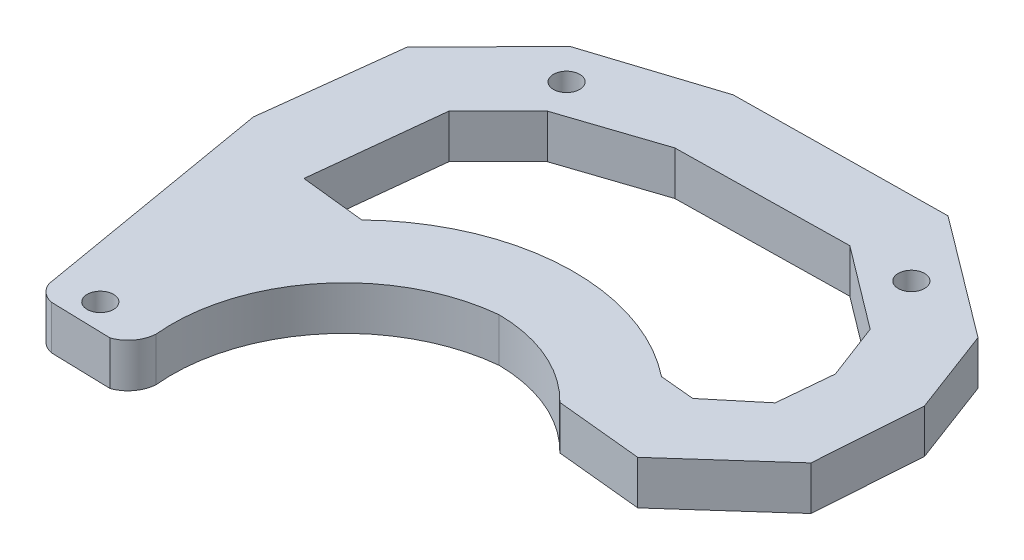
from build123d import *

# Parameters (mm, degrees)
BOSS_EXTRUDE2_DEPTH = 5
SKETCH2_R           = 1.5
CUT_EXTRUDE1_DEPTH  = 15


with BuildPart() as part:
    # Sketch1 → Boss-Extrude2 (new body)
    with BuildSketch(Plane(origin=(0, 0, 0), x_dir=(1, 0, 0), z_dir=(0, 1, 0))):
        with BuildLine():
            Line((1.569728042, 52.040332943), (15.651301799, 56.559771658))
            Line((15.651301799, 56.559771658), (39.856221019, 56.858644564))
            Line((39.856221019, 56.858644564), (53.599377939, 46.535137731))
            Line((53.599377939, 46.535137731), (57.29105631, 36.738583337))
            Line((57.29105631, 36.738583337), (56.448543902, 24.628756692))
            Line((56.448543902, 24.628756692), (46.012568554, 15.301947443))
            Line((46.012568554, 15.301947443), (36.148543795, 16.282769063))
            ThreePointArc((36.148543795, 16.282769063), (30.610071526, 20.095537749), (24.030369651, 21.480963085))
            ThreePointArc((24.030369651, 21.480963085), (10.748506444, 14.399234116), (6.364349479, 0))
            ThreePointArc((6.364349479, 0), (5.689983794, -1.843684392), (4.107122834, -3.004930446))
            Line((4.107122834, -3.004930446), (-2.771373889, -2.820272816))
            ThreePointArc((-2.771373889, -2.820272816), (-3.97819548, -2.210628496), (-4.733361209, -1.089107533))
            Line((-4.733361209, -1.089107533), (-9.544633948, 27.008719122))
            Line((-9.544633948, 27.008719122), (-7.668325905, 42.684434119))
            Line((-7.668325905, 42.684434119), (1.569728042, 52.040332943))
        make_face()
        with BuildLine():
            Line((1.036932163, 38.743694932), (-0.578535299, 23.81135118))
            Line((-0.578535299, 23.81135118), (6.824389086, 23.010459929))
            ThreePointArc((6.824389086, 23.010459929), (22.804886304, 29.960497456), (39.395602183, 24.628756692))
            Line((39.395602183, 24.628756692), (43.340115732, 24.258511233))
            Line((43.340115732, 24.258511233), (48.476214586, 28.525175745))
            Line((48.476214586, 28.525175745), (49.056861781, 34.804762264))
            Line((49.056861781, 34.804762264), (46.61935743, 41.212721012))
            Line((46.61935743, 41.212721012), (37.197706882, 48.312593262))
            Line((37.197706882, 48.312593262), (17.555979737, 47.985159309))
            Line((17.555979737, 47.985159309), (6.642360366, 44.349123135))
            Line((6.642360366, 44.349123135), (1.036932163, 38.743694932))
        make_face(mode=Mode.SUBTRACT)
    extrude(amount=BOSS_EXTRUDE2_DEPTH)

    # Sketch2 → Cut-Extrude1 (cut)
    with BuildSketch(Plane(origin=(0, 5, 0), x_dir=(1, 0, 0), z_dir=(0, 1, 0))):
        with Locations((44.194472597, 48.335123533)):
            Circle(SKETCH2_R)
        Circle(SKETCH2_R)
        with Locations((4.859386625, 48.335123533)):
            Circle(SKETCH2_R)
    extrude(amount=-CUT_EXTRUDE1_DEPTH, mode=Mode.SUBTRACT)


solid = part.part
